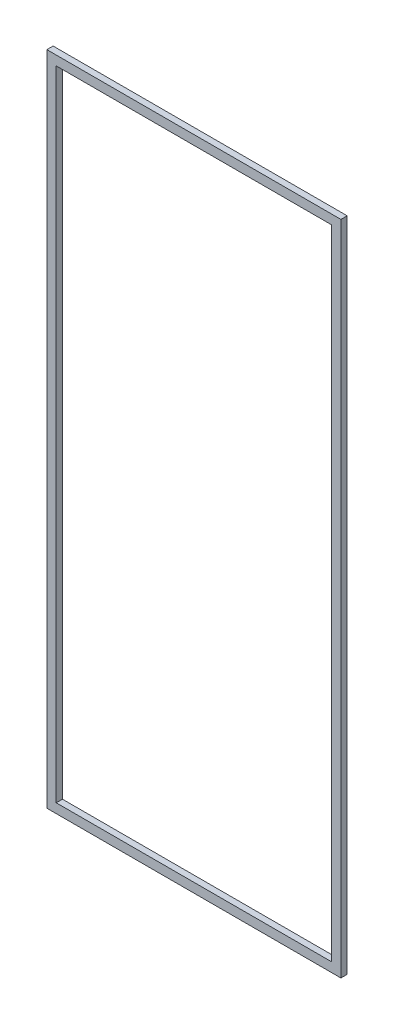
from build123d import *

# Parameters (mm, degrees)
SKETCH_1_W      = 470
SKETCH_1_H      = 1050
SKETCH_1_W_2    = 440
SKETCH_1_H_2    = 1020
EXTRUDE_1_DEPTH = 10


with BuildPart() as part:
    # Эскиз1 → Вытянуть-Тонкостенный1 (new body)
    with BuildSketch(Plane.XY):
        Rectangle(SKETCH_1_W, SKETCH_1_H)
        Rectangle(SKETCH_1_W_2, SKETCH_1_H_2, mode=Mode.SUBTRACT)
    extrude(amount=EXTRUDE_1_DEPTH)


solid = part.part
